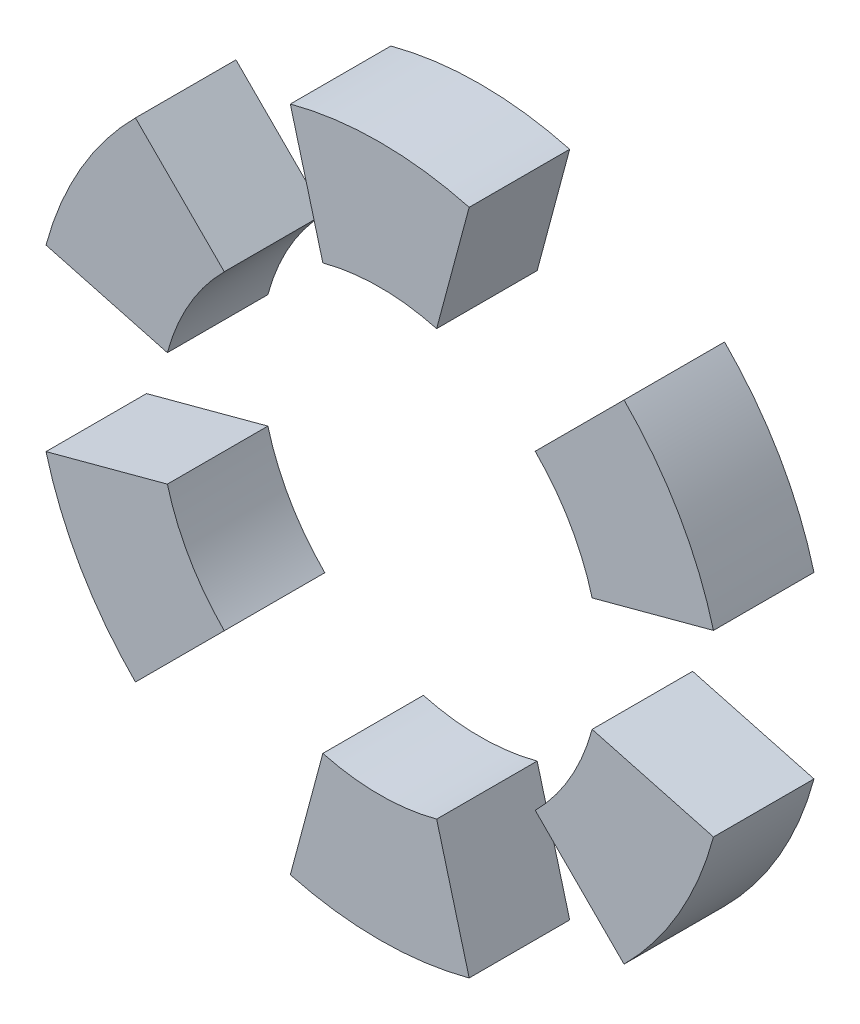
from build123d import *

# Parameters (mm, degrees)
BOSS_EXTRUDE1_DEPTH   = 8
BOSS_EXTRUDE1_2_DEPTH = 8
BOSS_EXTRUDE1_3_DEPTH = 8
BOSS_EXTRUDE1_4_DEPTH = 8
BOSS_EXTRUDE1_5_DEPTH = 8
BOSS_EXTRUDE1_6_DEPTH = 8


with BuildPart() as part:
    # Sketch1 → Boss-Extrude1 (new body)
    with BuildSketch(Plane.XY):
        with BuildLine():
            Line((-4.529333289, 16.90370196), (-7.11752374, 26.562960223))
            ThreePointArc((-7.11752374, 26.562960223), (0, 27.5), (7.11752374, 26.562960223))
            Line((7.11752374, 26.562960223), (4.529333289, 16.90370196))
            ThreePointArc((4.529333289, 16.90370196), (0, 17.5), (-4.529333289, 16.90370196))
        make_face()
    extrude(amount=BOSS_EXTRUDE1_DEPTH)


with BuildPart() as body_2:
    # Sketch1 → Boss-Extrude1 2 (new body)
    with BuildSketch(Plane.XY):
        with BuildLine():
            Line((12.374368671, 12.374368671), (19.445436483, 19.445436483))
            ThreePointArc((19.445436483, 19.445436483), (23.815698604, 13.75), (26.562960223, 7.11752374))
            Line((26.562960223, 7.11752374), (16.90370196, 4.529333289))
            ThreePointArc((16.90370196, 4.529333289), (15.155444566, 8.75), (12.374368671, 12.374368671))
        make_face()
    extrude(amount=BOSS_EXTRUDE1_2_DEPTH)


with BuildPart() as body_3:
    # Sketch1 → Boss-Extrude1 3 (new body)
    with BuildSketch(Plane.XY):
        with BuildLine():
            Line((16.90370196, -4.529333289), (26.562960223, -7.11752374))
            ThreePointArc((26.562960223, -7.11752374), (23.815698604, -13.75), (19.445436483, -19.445436483))
            Line((19.445436483, -19.445436483), (12.374368671, -12.374368671))
            ThreePointArc((12.374368671, -12.374368671), (15.155444566, -8.75), (16.90370196, -4.529333289))
        make_face()
    extrude(amount=BOSS_EXTRUDE1_3_DEPTH)


with BuildPart() as body_4:
    # Sketch1 → Boss-Extrude1 4 (new body)
    with BuildSketch(Plane.XY):
        with BuildLine():
            Line((4.529333289, -16.90370196), (7.11752374, -26.562960223))
            ThreePointArc((7.11752374, -26.562960223), (0, -27.5), (-7.11752374, -26.562960223))
            Line((-7.11752374, -26.562960223), (-4.529333289, -16.90370196))
            ThreePointArc((-4.529333289, -16.90370196), (0, -17.5), (4.529333289, -16.90370196))
        make_face()
    extrude(amount=BOSS_EXTRUDE1_4_DEPTH)


with BuildPart() as body_5:
    # Sketch1 → Boss-Extrude1 5 (new body)
    with BuildSketch(Plane.XY):
        with BuildLine():
            Line((-12.374368671, -12.374368671), (-19.445436483, -19.445436483))
            ThreePointArc((-19.445436483, -19.445436483), (-23.815698604, -13.75), (-26.562960223, -7.11752374))
            Line((-26.562960223, -7.11752374), (-16.90370196, -4.529333289))
            ThreePointArc((-16.90370196, -4.529333289), (-15.155444566, -8.75), (-12.374368671, -12.374368671))
        make_face()
    extrude(amount=BOSS_EXTRUDE1_5_DEPTH)


with BuildPart() as body_6:
    # Sketch1 → Boss-Extrude1 6 (new body)
    with BuildSketch(Plane.XY):
        with BuildLine():
            Line((-16.90370196, 4.529333289), (-26.562960223, 7.11752374))
            ThreePointArc((-26.562960223, 7.11752374), (-23.815698604, 13.75), (-19.445436483, 19.445436483))
            Line((-19.445436483, 19.445436483), (-12.374368671, 12.374368671))
            ThreePointArc((-12.374368671, 12.374368671), (-15.155444566, 8.75), (-16.90370196, 4.529333289))
        make_face()
    extrude(amount=BOSS_EXTRUDE1_6_DEPTH)


solid = Compound([part.part, body_2.part, body_3.part, body_4.part, body_5.part, body_6.part])
